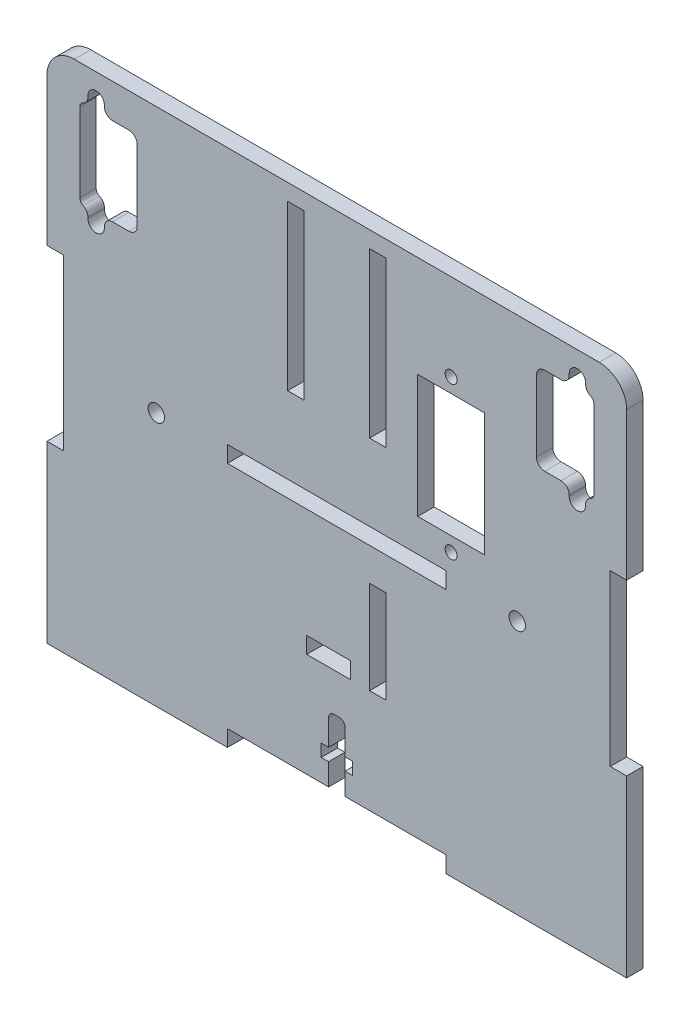
from build123d import *

# Parameters (mm, degrees)
ESBO_O1_W                = 100
ESBO_O1_H                = 95
RESSALTO_EXTRUS_O1_DEPTH = 1.5
ESBO_O2_R                = 1.5
ESBO_O2_W                = 40
ESBO_O2_H                = 3
CORTE_EXTRUS_O1_DEPTH    = 4
ESBO_O3_W                = 3
ESBO_O3_H                = 32
RESSALTO_EXTRUS_O2_DEPTH = 3
CUT_EXTRUDE1_DEPTH       = 1
CUT_EXTRUDE1_DEPTH_BACK  = 4
CUT_EXTRUDE4_DEPTH       = 2.5
CUT_EXTRUDE4_DEPTH_BACK  = 2.5
FILLET1_R                = 5
SKETCH3_W                = 3
SKETCH3_H                = 30
SKETCH3_H_2              = 17
SKETCH3_W_2              = 8
SKETCH3_H_3              = 3
CUT_EXTRUDE5_DEPTH       = 2.5
CUT_EXTRUDE5_DEPTH_BACK  = 2.5
SKETCH4_R                = 1.1
SKETCH4_W                = 12.2
SKETCH4_H                = 22.5
CUT_EXTRUDE6_DEPTH       = 1
CUT_EXTRUDE6_DEPTH_BACK  = 4


with BuildPart() as part:
    # Esboço1 → Ressalto-extrusão1 (new body, symmetric)
    with BuildSketch(Plane.XY):
        Rectangle(ESBO_O1_W, ESBO_O1_H)
    extrude(amount=RESSALTO_EXTRUS_O1_DEPTH, both=True)

    # Esboço2 → Corte-extrusão1 (cut, through all)
    with BuildSketch(Plane.XY.offset(1.5)):
        with Locations((-33, -1)):
            Circle(ESBO_O2_R)
        with Locations((33, -1)):
            Circle(ESBO_O2_R)
        with Locations((0, -46)):
            Rectangle(ESBO_O2_W, ESBO_O2_H)
        with Locations((0, -1)):
            Rectangle(ESBO_O2_W, ESBO_O2_H)
    extrude(amount=-CORTE_EXTRUS_O1_DEPTH, mode=Mode.SUBTRACT)

    # Esboço3 → Ressalto-extrusão2 (add, through all)
    with BuildSketch(Plane.XY.offset(1.5)):
        with Locations((-51.5, -31.5)):
            Rectangle(ESBO_O3_W, ESBO_O3_H)
        with Locations((51.5, -31.5)):
            Rectangle(ESBO_O3_W, ESBO_O3_H)
        with Locations((-51.5, 31.5)):
            Rectangle(ESBO_O3_W, ESBO_O3_H)
        with Locations((51.5, 31.5)):
            Rectangle(ESBO_O3_W, ESBO_O3_H)
    extrude(amount=-RESSALTO_EXTRUS_O2_DEPTH)

    # Sketch1 → Cut-Extrude1 (cut, two sides)
    with BuildSketch(Plane(origin=(0, 0, -1.5), x_dir=(-1, 0, 0), z_dir=(0, 0, -1))) as cut_extrude1_sk:
        with BuildLine():
            Line((-36.5, 39.75), (-36.5, 26.75))
            ThreePointArc((-36.5, 26.75), (-36.939339828, 25.689339828), (-38, 25.25))
            Line((-38, 25.25), (-41, 25.25))
            ThreePointArc((-41, 25.25), (-42.060660172, 24.810660172), (-42.5, 23.75))
            Line((-42.5, 23.75), (-42.5, 23.5))
            ThreePointArc((-42.5, 23.5), (-44, 22), (-45.5, 23.5))
            Line((-45.5, 23.5), (-45.5, 23.75))
            ThreePointArc((-45.5, 23.75), (-45.74500996, 24.571583836), (-46.4, 25.124772708))
            ThreePointArc((-46.4, 25.124772708), (-46.836660027, 25.49356529), (-47, 26.041287847))
            Line((-47, 26.041287847), (-47, 40.458712153))
            ThreePointArc((-47, 40.458712153), (-46.836660027, 41.00643471), (-46.4, 41.375227292))
            ThreePointArc((-46.4, 41.375227292), (-45.74500996, 41.928416164), (-45.5, 42.75))
            Line((-45.5, 42.75), (-45.5, 43))
            ThreePointArc((-45.5, 43), (-44, 44.5), (-42.5, 43))
            Line((-42.5, 43), (-42.5, 42.75))
            ThreePointArc((-42.5, 42.75), (-42.060660172, 41.689339828), (-41, 41.25))
            Line((-41, 41.25), (-38, 41.25))
            ThreePointArc((-38, 41.25), (-36.939339828, 40.810660172), (-36.5, 39.75))
        make_face()
        with BuildLine():
            Line((47, 40.458712153), (47, 26.041287847))
            ThreePointArc((47, 26.041287847), (46.836660027, 25.49356529), (46.4, 25.124772708))
            ThreePointArc((46.4, 25.124772708), (45.74500996, 24.571583836), (45.5, 23.75))
            Line((45.5, 23.75), (45.5, 23.5))
            ThreePointArc((45.5, 23.5), (44, 22), (42.5, 23.5))
            Line((42.5, 23.5), (42.5, 23.75))
            ThreePointArc((42.5, 23.75), (42.060660172, 24.810660172), (41, 25.25))
            Line((41, 25.25), (38, 25.25))
            ThreePointArc((38, 25.25), (36.939339828, 25.689339828), (36.5, 26.75))
            Line((36.5, 26.75), (36.5, 39.75))
            ThreePointArc((36.5, 39.75), (36.939339828, 40.810660172), (38, 41.25))
            Line((38, 41.25), (41, 41.25))
            ThreePointArc((41, 41.25), (42.060660172, 41.689339828), (42.5, 42.75))
            Line((42.5, 42.75), (42.5, 43))
            ThreePointArc((42.5, 43), (44, 44.5), (45.5, 43))
            Line((45.5, 43), (45.5, 42.75))
            ThreePointArc((45.5, 42.75), (45.74500996, 41.928416164), (46.4, 41.375227292))
            ThreePointArc((46.4, 41.375227292), (46.836660027, 41.00643471), (47, 40.458712153))
        make_face()
    extrude(amount=CUT_EXTRUDE1_DEPTH, mode=Mode.SUBTRACT)
    extrude(cut_extrude1_sk.sketch, amount=-CUT_EXTRUDE1_DEPTH_BACK, mode=Mode.SUBTRACT)

    # Sketch2 → Cut-Extrude4 (cut, two sides)
    with BuildSketch(Plane.XY) as cut_extrude4_sk:
        with BuildLine():
            Line((-0.5, -32.5), (0.5, -32.5))
            ThreePointArc((0.5, -32.5), (1.207106781, -32.792893219), (1.5, -33.5))
            Line((1.5, -33.5), (1.5, -38.23))
            Line((1.5, -38.23), (2.85, -38.23))
            Line((2.85, -38.23), (2.85, -40.5))
            Line((2.85, -40.5), (1.5, -40.5))
            Line((1.5, -40.5), (1.5, -44.5))
            Line((1.5, -44.5), (-1.5, -44.5))
            Line((-1.5, -44.5), (-1.5, -40.5))
            Line((-1.5, -40.5), (-2.85, -40.5))
            Line((-2.85, -40.5), (-2.85, -38.23))
            Line((-2.85, -38.23), (-1.5, -38.23))
            Line((-1.5, -38.23), (-1.5, -33.5))
            ThreePointArc((-1.5, -33.5), (-1.207106781, -32.792893219), (-0.5, -32.5))
        make_face()
    extrude(amount=CUT_EXTRUDE4_DEPTH, mode=Mode.SUBTRACT)
    extrude(cut_extrude4_sk.sketch, amount=-CUT_EXTRUDE4_DEPTH_BACK, mode=Mode.SUBTRACT)

    # Fillet1
    fillet1_edges = [part.edges().sort_by_distance(p)[0] for p in [
        (53, 47.5, 0),
        (-53, 47.5, 0),
    ]]
    fillet(fillet1_edges, radius=FILLET1_R)

    # Sketch3 → Cut-Extrude5 (cut, two sides)
    with BuildSketch(Plane.XY) as cut_extrude5_sk:
        with Locations((7.5, 29.5)):
            Rectangle(SKETCH3_W, SKETCH3_H)
        with Locations((7.5, -17)):
            Rectangle(SKETCH3_W, SKETCH3_H_2)
        with Locations((-7.5, 29.5)):
            Rectangle(SKETCH3_W, SKETCH3_H)
        with Locations((-1.5, -24)):
            Rectangle(SKETCH3_W_2, SKETCH3_H_3)
    extrude(amount=CUT_EXTRUDE5_DEPTH, mode=Mode.SUBTRACT)
    extrude(cut_extrude5_sk.sketch, amount=-CUT_EXTRUDE5_DEPTH_BACK, mode=Mode.SUBTRACT)

    # Sketch4 → Cut-Extrude6 (cut, two sides)
    with BuildSketch(Plane.XY.offset(1.5)) as cut_extrude6_sk:
        with Locations((20.9, 31.65)):
            Circle(SKETCH4_R)
        with Locations((20.9, 3.85)):
            Circle(SKETCH4_R)
        with Locations((20.9, 17.75)):
            Rectangle(SKETCH4_W, SKETCH4_H)
    extrude(amount=CUT_EXTRUDE6_DEPTH, mode=Mode.SUBTRACT)
    extrude(cut_extrude6_sk.sketch, amount=-CUT_EXTRUDE6_DEPTH_BACK, mode=Mode.SUBTRACT)


solid = part.part
